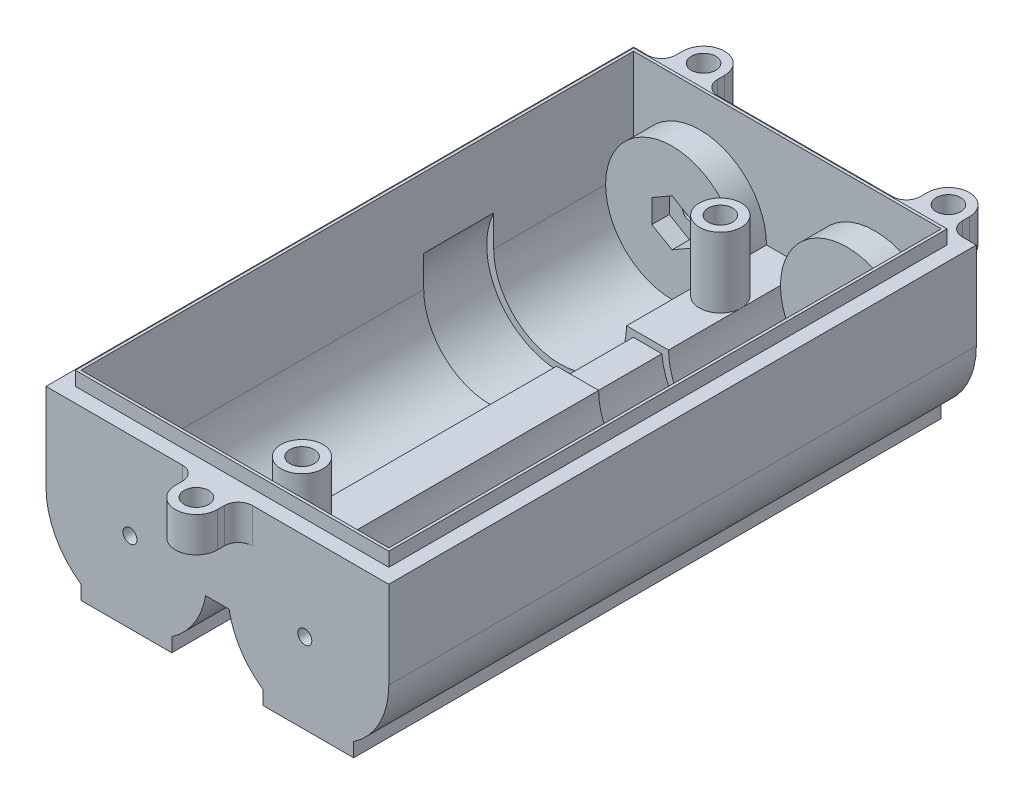
from build123d import *

# Parameters (mm, degrees)
SKETCH_1_R          = 1.75
SKETCH_1_W          = 44
SKETCH_1_H          = 79
EXTRUDE_1_DEPTH     = 5
SKETCH_2_W          = 49
SKETCH_2_H          = 84
SKETCH_2_W_2        = 44
SKETCH_2_H_2        = 79
EXTRUDE_2_DEPTH     = 17
SKETCH_3_W          = 44.8
SKETCH_3_H          = 79.8
SKETCH_3_W_2        = 44
SKETCH_3_H_2        = 79
EXTRUDE_3_DEPTH     = 2
SKETCH_4_W          = 49
SKETCH_4_H          = 84
EXTRUDE_4_DEPTH     = 2
EXTRUDE_5_DEPTH     = 79
CUT_EXTRUDE_START   = 20
CUT_EXTRUDE_1_DEPTH = 10
SKETCH_7_R          = 1.75
CUT_EXTRUDE_2_DEPTH = 12.5
CUT_EXTRUDE_3_DEPTH = 91
SKETCH_9_R          = 3
SKETCH_9_R_2        = 1.75
EXTRUDE_6_DEPTH     = 10
SKETCH_11_W         = 6
SKETCH_11_H         = 10
SKETCH_11_R         = 1.75
EXTRUDE_7_DEPTH     = 3.5
CUT_EXTRUDE_4_DEPTH = 3.5
SKETCH_13_R         = 9.5
EXTRUDE_8_DEPTH     = 4
SKETCH_14_R         = 9.5
EXTRUDE_9_DEPTH     = 4
CUT_EXTRUDE_5_DEPTH = 2.5
SKETCH_16_R         = 1
CUT_EXTRUDE_6_DEPTH = 11
SKETCH_17_R         = 3.75
CUT_EXTRUDE_7_DEPTH = 3
SKETCH_18_R         = 1
CUT_EXTRUDE_8_DEPTH = 10.5


with BuildPart() as part:
    # Эскиз1 → Бобышка-Вытянуть1 (new body)
    with BuildSketch(Plane(origin=(0, 0, 0), x_dir=(1, 0, 0), z_dir=(0, 1, 0))):
        with BuildLine():
            Line((-3, -45), (-3, -44))
            ThreePointArc((-3, -44), (-3.585786438, -42.585786438), (-5, -42))
            Line((-5, -42), (-24.5, -42))
            Line((-24.5, -42), (-24.5, 42))
            Line((-24.5, 42), (-22.5, 42))
            ThreePointArc((-22.5, 42), (-21.085786438, 42.585786438), (-20.5, 44))
            Line((-20.5, 44), (-20.5, 45))
            ThreePointArc((-20.5, 45), (-17.5, 48), (-14.5, 45))
            Line((-14.5, 45), (-14.5, 44))
            ThreePointArc((-14.5, 44), (-13.914213562, 42.585786438), (-12.5, 42))
            Line((-12.5, 42), (12.5, 42))
            ThreePointArc((12.5, 42), (13.914213562, 42.585786438), (14.5, 44))
            Line((14.5, 44), (14.5, 45))
            ThreePointArc((14.5, 45), (17.5, 48), (20.5, 45))
            Line((20.5, 45), (20.5, 44))
            ThreePointArc((20.5, 44), (21.085786438, 42.585786438), (22.5, 42))
            Line((22.5, 42), (24.5, 42))
            Line((24.5, 42), (24.5, -42))
            Line((24.5, -42), (5, -42))
            ThreePointArc((5, -42), (3.585786438, -42.585786438), (3, -44))
            Line((3, -44), (3, -45))
            ThreePointArc((3, -45), (0, -48), (-3, -45))
        make_face()
        with Locations((-17.5, 45)):
            Circle(SKETCH_1_R, mode=Mode.SUBTRACT)
        with Locations((17.5, 45)):
            Circle(SKETCH_1_R, mode=Mode.SUBTRACT)
        with Locations((0, -45)):
            Circle(SKETCH_1_R, mode=Mode.SUBTRACT)
        Rectangle(SKETCH_1_W, SKETCH_1_H, mode=Mode.SUBTRACT)
    extrude(amount=EXTRUDE_1_DEPTH)

    # Эскиз2 → Бобышка-Вытянуть2 (add)
    with BuildSketch(Plane.XZ):
        Rectangle(SKETCH_2_W, SKETCH_2_H)
        Rectangle(SKETCH_2_W_2, SKETCH_2_H_2, mode=Mode.SUBTRACT)
    extrude(amount=EXTRUDE_2_DEPTH)

    # Эскиз3 → Бобышка-Вытянуть3 (add)
    with BuildSketch(Plane(origin=(0, 5, 0), x_dir=(1, 0, 0), z_dir=(0, 1, 0))):
        Rectangle(SKETCH_3_W, SKETCH_3_H)
        Rectangle(SKETCH_3_W_2, SKETCH_3_H_2, mode=Mode.SUBTRACT)
    extrude(amount=EXTRUDE_3_DEPTH)

    # Эскиз4 → Бобышка-Вытянуть4 (add)
    with BuildSketch(Plane.XZ.offset(17)):
        Rectangle(SKETCH_4_W, SKETCH_4_H)
    extrude(amount=EXTRUDE_4_DEPTH)

    # Эскиз5 → Бобышка-Вытянуть5 (add)
    with BuildSketch(Plane.XY.offset(-39.5)):
        with BuildLine():
            Line((3, -7.5), (-3, -7.5))
            ThreePointArc((-3, -7.5), (-5.782485579, -14.217514421), (-12.5, -17))
            Line((-12.5, -17), (12.5, -17))
            ThreePointArc((12.5, -17), (5.782485579, -14.217514421), (3, -7.5))
        make_face()
        with BuildLine():
            Line((-22, -17), (-12.5, -17))
            ThreePointArc((-12.5, -17), (-19.217514421, -14.217514421), (-22, -7.5))
            Line((-22, -7.5), (-22, -17))
        make_face()
        with BuildLine():
            ThreePointArc((22, -7.5), (19.217514421, -14.217514421), (12.5, -17))
            Line((12.5, -17), (22, -17))
            Line((22, -17), (22, -7.5))
        make_face()
    extrude(amount=EXTRUDE_5_DEPTH)

    # Эскиз6 → Вырез-Вытянуть1 (cut)
    with BuildSketch(Plane.XY.offset(-39.5).offset(CUT_EXTRUDE_START)):
        with BuildLine():
            Line((-2.042513515, -8.443915466), (2.042513515, -8.443915466))
            ThreePointArc((2.042513515, -8.443915466), (20.251164828, -14.583039164), (12.5, 3))
            Line((12.5, 3), (-12.5, 3))
            ThreePointArc((-12.5, 3), (-20.251164828, -14.583039164), (-2.042513515, -8.443915466))
        make_face()
    extrude(amount=CUT_EXTRUDE_1_DEPTH, mode=Mode.SUBTRACT)

    # Эскиз7 → Вырез-Вытянуть2 (cut, through all)
    with BuildSketch(Plane(origin=(0, -7.5, 0), x_dir=(1, 0, 0), z_dir=(0, 1, 0))):
        with Locations((0, 29.9)):
            Circle(SKETCH_7_R)
        with Locations((0, -29.9)):
            Circle(SKETCH_7_R)
    extrude(amount=-CUT_EXTRUDE_2_DEPTH, mode=Mode.SUBTRACT)

    # Эскиз8 → Вырез-Вытянуть3 (cut, through all)
    with BuildSketch(Plane.XY.offset(42)):
        with BuildLine():
            Line((-1.675248347, -9.5), (1.675248347, -9.5))
            ThreePointArc((1.675248347, -9.5), (3.339700343, -13.739279648), (6.519259302, -17))
            Line((6.519259302, -17), (6.519259302, -19))
            Line((6.519259302, -19), (-6.519259302, -19))
            Line((-6.519259302, -19), (-6.519259302, -17))
            ThreePointArc((-6.519259302, -17), (-3.339700343, -13.739279648), (-1.675248347, -9.5))
        make_face()
        with BuildLine():
            Line((19.480740698, -19), (24.5, -19))
            Line((24.5, -19), (24.5, -7.5))
            ThreePointArc((24.5, -7.5), (23.168050896, -12.872219372), (19.480740698, -17))
            Line((19.480740698, -17), (19.480740698, -19))
        make_face()
        with BuildLine():
            Line((-24.5, -7.5), (-24.5, -19))
            Line((-24.5, -19), (-19.480740698, -19))
            Line((-19.480740698, -19), (-19.480740698, -17))
            ThreePointArc((-19.480740698, -17), (-23.168050896, -12.872219372), (-24.5, -7.5))
        make_face()
    extrude(amount=-CUT_EXTRUDE_3_DEPTH, mode=Mode.SUBTRACT)

    # Эскиз9 → Бобышка-Вытянуть6 (add)
    with BuildSketch(Plane(origin=(0, -7.5, 0), x_dir=(1, 0, 0), z_dir=(0, 1, 0))):
        with Locations((0, 29.9)):
            Circle(SKETCH_9_R)
        with Locations((0, 29.9)):
            Circle(SKETCH_9_R_2, mode=Mode.SUBTRACT)
        with Locations((0, -29.9)):
            Circle(SKETCH_9_R)
        with Locations((0, -29.9)):
            Circle(SKETCH_9_R_2, mode=Mode.SUBTRACT)
    extrude(amount=EXTRUDE_6_DEPTH)

    # Эскиз11 → Бобышка-Вытянуть7 (add)
    with BuildSketch(Plane.XZ.offset(9.5)):
        with Locations((0, -29.9)):
            Rectangle(SKETCH_11_W, SKETCH_11_H)
        with Locations((0, -29.9)):
            Circle(SKETCH_11_R, mode=Mode.SUBTRACT)
        with Locations((0, 29.9)):
            Rectangle(SKETCH_11_W, SKETCH_11_H)
        with Locations((0, 29.9)):
            Circle(SKETCH_11_R, mode=Mode.SUBTRACT)
    extrude(amount=EXTRUDE_7_DEPTH)

    # Эскиз12 → Вырез-Вытянуть4 (cut)
    with BuildSketch(Plane.XZ.offset(13)):
        Polygon((0, 26.574462449), (2.88, 28.237231225), (2.88, 31.562768775), (0, 33.225537551), (-2.88, 31.562768775), (-2.88, 28.237231225), align=None)
        Polygon((0, -33.225537551), (2.88, -31.562768775), (2.88, -28.237231225), (0, -26.574462449), (-2.88, -28.237231225), (-2.88, -31.562768775), align=None)
    extrude(amount=-CUT_EXTRUDE_4_DEPTH, mode=Mode.SUBTRACT)

    # Эскиз13 → Бобышка-Вытянуть8 (add)
    with BuildSketch(Plane.XY.offset(-39.5)):
        with Locations((-12.5, -7.5)):
            Circle(SKETCH_13_R)
        with Locations((12.5, -7.5)):
            Circle(SKETCH_13_R)
    extrude(amount=EXTRUDE_8_DEPTH)

    # Эскиз14 → Бобышка-Вытянуть9 (add)
    with BuildSketch(Plane(origin=(0, 0, 39.5), x_dir=(-1, 0, 0), z_dir=(0, 0, -1))):
        with Locations((-12.5, -7.5)):
            Circle(SKETCH_14_R)
        with Locations((12.5, -7.5)):
            Circle(SKETCH_14_R)
    extrude(amount=EXTRUDE_9_DEPTH)

    # Эскиз15 → Вырез-Вытянуть5 (cut)
    with BuildSketch(Plane.XY.offset(-35.5)):
        Polygon((-12.5, -10.848631561), (-9.6, -9.174315781), (-9.6, -5.825684219), (-12.5, -4.151368439), (-15.4, -5.825684219), (-15.4, -9.174315781), align=None)
        Polygon((12.5, -10.848631561), (15.4, -9.174315781), (15.4, -5.825684219), (12.5, -4.151368439), (9.6, -5.825684219), (9.6, -9.174315781), align=None)
    extrude(amount=-CUT_EXTRUDE_5_DEPTH, mode=Mode.SUBTRACT)

    # Эскиз16 → Вырез-Вытянуть6 (cut, through all)
    with BuildSketch(Plane.XY.offset(-38)):
        with Locations((12.5, -7.5)):
            Circle(SKETCH_16_R)
        with Locations((-12.5, -7.5)):
            Circle(SKETCH_16_R)
    extrude(amount=-CUT_EXTRUDE_6_DEPTH, mode=Mode.SUBTRACT)

    # Эскиз17 → Вырез-Вытянуть7 (cut)
    with BuildSketch(Plane(origin=(0, 0, 35.5), x_dir=(-1, 0, 0), z_dir=(0, 0, -1))):
        with Locations((-12.5, -7.5)):
            Circle(SKETCH_17_R)
        with Locations((12.5, -7.5)):
            Circle(SKETCH_17_R)
    extrude(amount=-CUT_EXTRUDE_7_DEPTH, mode=Mode.SUBTRACT)

    # Эскиз18 → Вырез-Вытянуть8 (cut, through all)
    with BuildSketch(Plane(origin=(0, 0, 38.5), x_dir=(-1, 0, 0), z_dir=(0, 0, -1))):
        with Locations((-12.5, -7.5)):
            Circle(SKETCH_18_R)
        with Locations((12.5, -7.5)):
            Circle(SKETCH_18_R)
    extrude(amount=-CUT_EXTRUDE_8_DEPTH, mode=Mode.SUBTRACT)


solid = part.part
